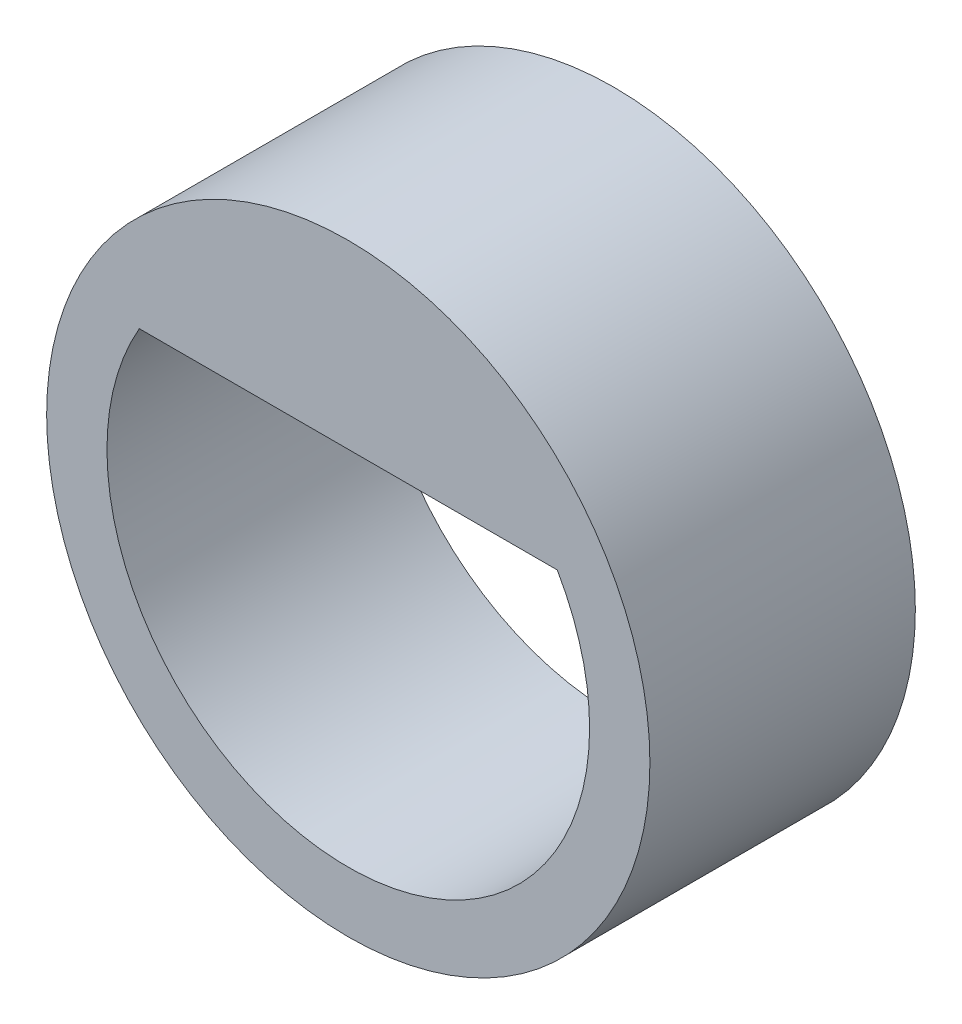
from build123d import *

# Parameters (mm, degrees)
SKETCH1_R           = 2.5
BOSS_EXTRUDE1_DEPTH = 2.2


with BuildPart() as part:
    # Sketch1 → Boss-Extrude1 (new body)
    with BuildSketch(Plane.XY):
        Circle(SKETCH1_R)
        with BuildLine():
            Line((-1.732050808, 1), (1.732050808, 1))
            ThreePointArc((1.732050808, 1), (0, -2), (-1.732050808, 1))
        make_face(mode=Mode.SUBTRACT)
    extrude(amount=BOSS_EXTRUDE1_DEPTH)


solid = part.part
